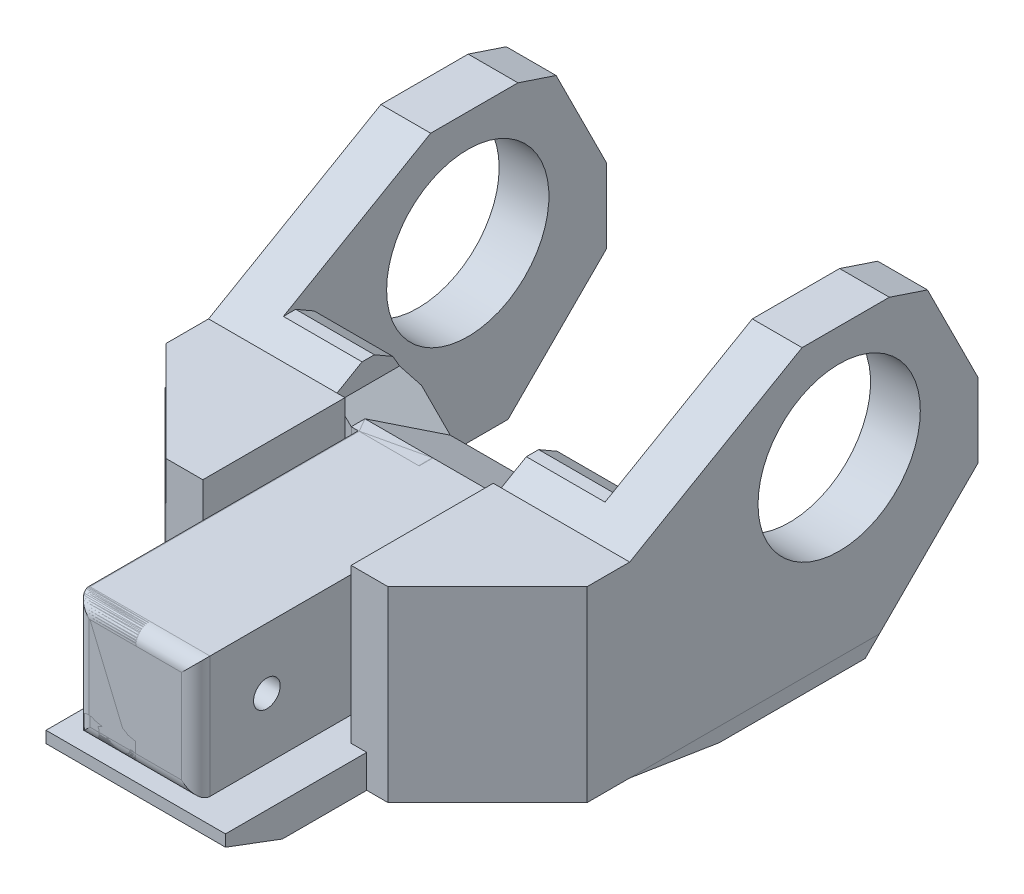
from build123d import *

# Parameters (mm, degrees)
BOSS_EXTRUDE1_DEPTH      = 21.73
BOSS_EXTRUDE2_DEPTH      = 23.229999974
BOSS_EXTRUDE2_DEPTH_BACK = 1.5
SKETCH2_W                = 19.05
SKETCH2_H                = 24.729999974
BOSS_EXTRUDE3_DEPTH      = 25.4
SKETCH3_W                = 6.35
SKETCH3_H                = 24.729999974
BOSS_EXTRUDE4_DEPTH      = 43.18
SKETCH4_W                = 19.05
SKETCH4_H                = 24.729999974
CUT_EXTRUDE1_DEPTH       = 14.05
SKETCH5_W                = 43.64
SKETCH5_H                = 24.729999974
BOSS_EXTRUDE5_DEPTH      = 7.62
BOSS_EXTRUDE6_DEPTH      = 8.789999946
BOSS_EXTRUDE7_DEPTH      = 20.219999946
SKETCH9_W                = 49.61
SKETCH9_H                = 53.739999866
BOSS_EXTRUDE8_DEPTH      = 2.54
SKETCH10_R               = 14.5
CUT_EXTRUDE2_DEPTH       = 44.704
FILLET3_R                = 2.54
CHAMFER1_SIZE            = 20.16
CHAMFER2_SIZE            = 20.32
CHAMFER2_SIZE2           = 10.16
SKETCH12_W               = 23.23
SKETCH12_H               = 21.71999992
CUT_EXTRUDE4_DEPTH       = 23.114
SKETCH13_W               = 12.62
SKETCH13_H               = 21.71999992
CUT_EXTRUDE5_DEPTH       = 3.81
CHAMFER4_SIZE            = 2.54
CHAMFER7_SIZE            = 17.78
CHAMFER7_SIZE2           = 30.795863359
CHAMFER8_SIZE            = 2.54
CHAMFER8_SIZE2           = 16.036928847
CHAMFER10_SIZE           = 12.7
CHAMFER10_SIZE2          = 6.35
SKETCH16_W               = 21.59
SKETCH16_H               = 33.419999866
BOSS_EXTRUDE9_DEPTH      = 25.4
BOSS_EXTRUDE10_DEPTH     = 25.4
CHAMFER12_SIZE           = 5.08
CHAMFER12_SIZE2          = 10.16
CHAMFER13_SIZE           = 2.54
CHAMFER13_SIZE2          = 5.679612663
SKETCH18_W               = 24.13
SKETCH18_H               = 29.479999946
BOSS_EXTRUDE11_DEPTH     = 25.4
SKETCH11_R               = 1.778
CUT_EXTRUDE9_DEPTH       = 131.296968124
CHAMFER14_SIZE           = 17.78
SKETCH19_W               = 29.67
SKETCH19_H               = 5.08
BOSS_EXTRUDE12_DEPTH     = 50.633268
CHAMFER15_SIZE           = 10.16
CHAMFER15_SIZE2          = 3.81
CUT_EXTRUDE10_DEPTH      = 122.202951668
CUT_EXTRUDE11_REACH      = 92.065
SKETCH21_W               = 24.13
SKETCH21_H               = 2.948571429
CUT_EXTRUDE13_DEPTH      = 26.67
CUT_EXTRUDE14_DEPTH      = 31.496
CHAMFER17_SIZE           = 2.54
CHAMFER17_SIZE2          = 4.399409051
CHAMFER18_SIZE           = 2.54
CHAMFER18_SIZE2          = 4.399409051
CHAMFER19_SIZE           = 1.27
SKETCH26_W               = 25.4
SKETCH26_H               = 28.339999866
BOSS_EXTRUDE13_DEPTH     = 2.785625036
BOSS_EXTRUDE14_DEPTH     = 0.8
SKETCH30_R               = 2.032
CUT_EXTRUDE16_DEPTH      = 89.17795503


with BuildPart() as part:
    # Sketch1 → Boss-Extrude1 (new body)
    with BuildSketch(Plane(origin=(0, 0, 0), x_dir=(1, 0, 0), z_dir=(0, 1, 0))):
        Polygon((-1.5, 40), (0, 40), (21.59, 40), (23.09, 40), (23.09, 45), (-1.5, 45), align=None)
        Polygon((0, 40), (0, 0), (0, -10.633268202), (21.59, -10.633268202), (21.59, 0), (21.59, 40), align=None)
    extrude(amount=BOSS_EXTRUDE1_DEPTH)

    # Sketch1_4 → Boss-Extrude2 (add, two sides)
    with BuildSketch(Plane(origin=(0, 0, 0), x_dir=(1, 0, 0), z_dir=(0, 1, 0))) as boss_extrude2_sk:
        Polygon((-1.5, 40), (0, 40), (21.59, 40), (23.09, 40), (23.09, 45), (-1.5, 45), align=None)
    extrude(amount=BOSS_EXTRUDE2_DEPTH)
    extrude(boss_extrude2_sk.sketch, amount=-BOSS_EXTRUDE2_DEPTH_BACK)

    # Sketch2 → Boss-Extrude3 (add)
    with BuildSketch(Plane(origin=(23.09, 0, 0), x_dir=(0, 0, -1), z_dir=(1, 0, 0))):
        with Locations((49.525, 10.864999987)):
            Rectangle(SKETCH2_W, SKETCH2_H)
    extrude(amount=BOSS_EXTRUDE3_DEPTH)

    # Sketch3 → Boss-Extrude4 (add)
    with BuildSketch(Plane(origin=(0, 0, -59.05), x_dir=(-1, 0, 0), z_dir=(0, 0, -1))):
        with Locations((-45.315, 10.864999987)):
            Rectangle(SKETCH3_W, SKETCH3_H)
    extrude(amount=BOSS_EXTRUDE4_DEPTH)

    # Sketch4 → Cut-Extrude1 (cut)
    with BuildSketch(Plane(origin=(0, 0, -59.05), x_dir=(-1, 0, 0), z_dir=(0, 0, -1))):
        with Locations((-32.615, 10.864999987)):
            Rectangle(SKETCH4_W, SKETCH4_H)
    extrude(amount=-CUT_EXTRUDE1_DEPTH, mode=Mode.SUBTRACT)

    # Sketch5 → Boss-Extrude5 (add)
    with BuildSketch(Plane(origin=(0, 0, -45), x_dir=(-1, 0, 0), z_dir=(0, 0, -1))):
        with Locations((-20.32, 10.864999987)):
            Rectangle(SKETCH5_W, SKETCH5_H)
    extrude(amount=BOSS_EXTRUDE5_DEPTH)

    # Sketch6 → Boss-Extrude6 (add)
    with BuildSketch(Plane.XZ.offset(1.5)):
        Polygon((-1.5, -40), (48.49, -40), (48.49, -46.27), (48.49, -102.23), (42.14, -102.23), (42.14, -52.62), (-1.5, -52.62), align=None)
    extrude(amount=BOSS_EXTRUDE6_DEPTH)

    # Sketch7 → Boss-Extrude7 (add)
    with BuildSketch(Plane(origin=(0, 23.229999974, 0), x_dir=(1, 0, 0), z_dir=(0, 1, 0))):
        Polygon((-1.5, 40), (48.49, 40), (48.49, 46.27), (48.49, 102.23), (42.14, 102.23), (42.14, 52.62), (-1.5, 52.62), align=None)
    extrude(amount=BOSS_EXTRUDE7_DEPTH)

    # Sketch9 → Boss-Extrude8 (add)
    with BuildSketch(Plane.ZY.offset(-42.14)):
        with Locations((-77.425, 16.579999987)):
            Rectangle(SKETCH9_W, SKETCH9_H)
    extrude(amount=BOSS_EXTRUDE8_DEPTH)

    # Sketch10 → Cut-Extrude2 (cut)
    with BuildSketch(Plane.ZY.offset(-39.6)):
        with Locations((-77.425, 23.12999992)):
            Circle(SKETCH10_R)
    extrude(amount=-CUT_EXTRUDE2_DEPTH, mode=Mode.SUBTRACT)

    # Fillet3
    fillet3_edges = [part.edges().sort_by_distance(p)[0] for p in [
        (10.795, 0, 10.633268202),
        (10.795, 21.73, 10.633268202),
        (21.59, 10.865, 10.633268202),
        (0, 10.865, 10.633268202),
    ]]
    fillet(fillet3_edges, radius=FILLET3_R)

    # Chamfer1
    chamfer1_edges = [part.edges().sort_by_distance(p)[0] for p in [
        (44.045, -10.289999946, -102.23),
    ]]
    chamfer(chamfer1_edges, length=CHAMFER1_SIZE)

    # Chamfer2
    chamfer2_edges = [part.edges().sort_by_distance(p)[0] for p in [
        (44.045, 43.44999992, -102.23),
    ]]
    chamfer2_side = [part.faces().sort_by_distance(p)[0] for p in [
        (44.045, 26.659999987, -102.23),
    ]]
    chamfer(chamfer2_edges, length=CHAMFER2_SIZE, length2=CHAMFER2_SIZE2, reference=chamfer2_side[0])

    # Sketch12 → Cut-Extrude4 (cut)
    with BuildSketch(Plane.XY.offset(-40)):
        with Locations((10.115, 32.58999996)):
            Rectangle(SKETCH12_W, SKETCH12_H)
    extrude(amount=-CUT_EXTRUDE4_DEPTH, mode=Mode.SUBTRACT)

    # Sketch13 → Cut-Extrude5 (cut)
    with BuildSketch(Plane.ZY.offset(-21.73)):
        with Locations((-46.31, 32.58999996)):
            Rectangle(SKETCH13_W, SKETCH13_H)
    extrude(amount=-CUT_EXTRUDE5_DEPTH, mode=Mode.SUBTRACT)

    # Chamfer4
    chamfer4_edges = [part.edges().sort_by_distance(p)[0] for p in [
        (25.54, 21.73, -46.31),
    ]]
    chamfer(chamfer4_edges, length=CHAMFER4_SIZE)

    # Chamfer7
    chamfer7_edges = [part.edges().sort_by_distance(p)[0] for p in [
        (37.015, 43.44999992, -40),
    ]]
    chamfer7_side = [part.faces().sort_by_distance(p)[0] for p in [
        (31.271893958, 12.476304807, -40),
    ]]
    chamfer(chamfer7_edges, length=CHAMFER7_SIZE, length2=CHAMFER7_SIZE2, reference=chamfer7_side[0])

    # Chamfer8
    chamfer8_edges = [part.edges().sort_by_distance(p)[0] for p in [
        (23.495, -10.289999946, -40),
    ]]
    chamfer8_side = [part.faces().sort_by_distance(p)[0] for p in [
        (29.3591267, 5.121230979, -40),
    ]]
    chamfer(chamfer8_edges, length=CHAMFER8_SIZE, length2=CHAMFER8_SIZE2, reference=chamfer8_side[0])

    # Chamfer10
    chamfer10_edges = [part.edges().sort_by_distance(p)[0] for p in [
        (39.6, 11.603674367, -52.62),
    ]]
    chamfer10_side = [part.faces().sort_by_distance(p)[0] for p in [
        (20.529332087, 8.343955773, -52.62),
    ]]
    chamfer(chamfer10_edges, length=CHAMFER10_SIZE, length2=CHAMFER10_SIZE2, reference=chamfer10_side[0])

    # Sketch16 → Boss-Extrude9 (add)
    with BuildSketch(Plane.XY.offset(-40)):
        with Locations((37.695, 8.959999987)):
            Rectangle(SKETCH16_W, SKETCH16_H)
    extrude(amount=BOSS_EXTRUDE9_DEPTH)

    # Sketch17 → Boss-Extrude10 (add)
    with BuildSketch(Plane.ZY.offset(1.5)):
        Polygon((-52.62, 21.73), (-52.62, -9.748811583), (-40, -7.749999946), (-40, 21.73), align=None)
    extrude(amount=BOSS_EXTRUDE10_DEPTH)

    # Chamfer12
    chamfer12_edges = [part.edges().sort_by_distance(p)[0] for p in [
        (-1.95, 21.73, -52.62),
    ]]
    chamfer12_side = [part.faces().sort_by_distance(p)[0] for p in [
        (0.280348521, 6.212260244, -52.62),
    ]]
    chamfer(chamfer12_edges, length=CHAMFER12_SIZE, length2=CHAMFER12_SIZE2, reference=chamfer12_side[0])

    # Chamfer13
    chamfer13_edges = [part.edges().sort_by_distance(p)[0] for p in [
        (44.045, 43.44999992, -92.07),
    ]]
    chamfer13_side = [part.faces().sort_by_distance(p)[0] for p in [
        (44.045, 33.28999992, -97.15),
    ]]
    chamfer(chamfer13_edges, length=CHAMFER13_SIZE, length2=CHAMFER13_SIZE2, reference=chamfer13_side[0])

    # Sketch18 → Boss-Extrude11 (add)
    with BuildSketch(Plane.XY.offset(-40)):
        with Locations((-14.835, 6.990000027)):
            Rectangle(SKETCH18_W, SKETCH18_H)
    extrude(amount=BOSS_EXTRUDE11_DEPTH)

    # Sketch11 → Cut-Extrude9 (cut, through all)
    with BuildSketch(Plane.XY.offset(10.633268202)):
        with Locations((2.54, 2.54)):
            Circle(SKETCH11_R)
    extrude(amount=-CUT_EXTRUDE9_DEPTH, mode=Mode.SUBTRACT)

    # Chamfer14
    chamfer14_edges = [part.edges().sort_by_distance(p)[0] for p in [
        (48.49, 8.959999987, -14.6),
        (-26.9, 6.990000027, -14.6),
    ]]
    chamfer(chamfer14_edges, length=CHAMFER14_SIZE)

    # Sketch19 → Boss-Extrude12 (add, through all)
    with BuildSketch(Plane.XY.offset(-40)):
        with Locations((12.065, -5.209999946)):
            Rectangle(SKETCH19_W, SKETCH19_H)
    extrude(amount=BOSS_EXTRUDE12_DEPTH)

    # Chamfer15
    chamfer15_edges = [part.edges().sort_by_distance(p)[0] for p in [
        (12.065, -7.749999946, 10.633268),
    ]]
    chamfer15_side = [part.faces().sort_by_distance(p)[0] for p in [
        (11.2000407, -7.749999946, -20.137931454),
    ]]
    chamfer(chamfer15_edges, length=CHAMFER15_SIZE, length2=CHAMFER15_SIZE2, reference=chamfer15_side[0])

    # Sketch20 → Cut-Extrude10 (cut, through all)
    with BuildSketch(Plane.ZY):
        with BuildLine():
            ThreePointArc((0.314518202, 10.865), (-0.382933775, 12.548798023), (-2.066731798, 13.24625))
            Line((-2.066731798, 13.24625), (-2.066731798, 10.865))
            Line((-2.066731798, 10.865), (0.314518202, 10.865))
        make_face()
        with BuildLine():
            Line((-2.066731798, 10.865), (-2.066731798, 13.24625))
            ThreePointArc((-2.066731798, 13.24625), (-3.750529821, 9.181201977), (0.314518202, 10.865))
            Line((0.314518202, 10.865), (-2.066731798, 10.865))
        make_face()
    extrude(amount=-CUT_EXTRUDE10_DEPTH, mode=Mode.SUBTRACT)

    # Cut-Extrude11: up to this face of the body (flat: up to its plane)
    cut_extrude11_end = Plane(part.part.faces().sort_by_distance((-5.945, 6.990000027, -14.6))[0])
    # Sketch21 → Cut-Extrude11 (cut, up to the picked face)
    with BuildSketch(Plane(origin=(0, 0, -40), x_dir=(-1, 0, 0), z_dir=(0, 0, -1)), mode=Mode.PRIVATE) as cut_extrude11_sk1:
        with Locations((14.835, 20.255714286)):
            Rectangle(SKETCH21_W, SKETCH21_H)
    cut_extrude11_tool1 = split(extrude(cut_extrude11_sk1.sketch, amount=-CUT_EXTRUDE11_REACH, mode=Mode.PRIVATE), bisect_by=cut_extrude11_end, keep=Keep.BOTH, mode=Mode.PRIVATE)
    add(cut_extrude11_tool1.solids().sort_by(Axis((-14.835, 20.255714, -40), (0, 0, 1)))[0], mode=Mode.SUBTRACT)


with BuildPart() as body_2:
    # Split1: the piece on the far side of the plane
    add(part.part)
    split(bisect_by=Plane(origin=(0, -7.749999946, 0), x_dir=(0, 0, -1), z_dir=(0, -1, 0)), keep=Keep.BOTTOM)


with BuildPart() as part_1:
    add(part.part)

    # Split1
    split(bisect_by=Plane(origin=(0, -7.749999946, 0), x_dir=(0, 0, -1), z_dir=(0, -1, 0)), keep=Keep.TOP)


with BuildPart() as body_3:
    # Split2: the piece on the far side of the plane
    add(body_2.part)
    split(bisect_by=Plane(origin=(10.865000114, 0, 0), x_dir=(0, 0, -1), z_dir=(-1, 0, 0)), keep=Keep.BOTTOM)


with BuildPart() as body_2_1:
    add(body_2.part)

    # Split2
    split(bisect_by=Plane(origin=(10.865000114, 0, 0), x_dir=(0, 0, -1), z_dir=(-1, 0, 0)), keep=Keep.TOP)


with BuildPart() as body_4:
    # Mirror2: mirrored copy
    add(body_3.part.mirror(Plane.ZY.offset(-10.865000114)))

    # Combine1: union body 3
    add(body_3.part)

    # Sketch24 → Cut-Extrude13 (cut)
    with BuildSketch(Plane(origin=(0, 1.931991864, 1.115436023), x_dir=(1, 0, 0), z_dir=(0, 0.8660254037844406, 0.4999999999999968))):
        Polygon((-3.809999772, 62.048336906), (-3.809999772, 56.460336906), (-17.869999772, 56.460336906), (-17.869999772, 69.380685324), (-5.169999772, 62.048336906), align=None)
    cut_extrude13 = extrude(amount=-CUT_EXTRUDE13_DEPTH, mode=Mode.SUBTRACT)

    # Mirror3: Cut-Extrude13 across plane
    add(cut_extrude13.mirror(Plane.ZY.offset(-10.865000114)), mode=Mode.SUBTRACT)

    # Sketch25 → Cut-Extrude14 (cut)
    with BuildSketch(Plane(origin=(25.54, 0, 0), x_dir=(0, 0, -1), z_dir=(1, 0, 0))):
        Polygon((52.62, 21.780160317), (51.182490389, 24.27), (52.62, 24.27), align=None)
    extrude(amount=-CUT_EXTRUDE14_DEPTH, mode=Mode.SUBTRACT)

    # Chamfer17
    chamfer17_edges = [body_4.edges().sort_by_distance(p)[0] for p in [
        (32.57, 30.162160317, -47.780650044),
    ]]
    chamfer17_side = [body_4.faces().sort_by_distance(p)[0] for p in [
        (40.768870369, 32.663150898, -52.112492799),
    ]]
    chamfer(chamfer17_edges, length=CHAMFER17_SIZE, length2=CHAMFER17_SIZE2, reference=chamfer17_side[0])

    # Chamfer18
    chamfer18_edges = [body_4.edges().sort_by_distance(p)[0] for p in [
        (-10.839999772, 30.162160317, -47.780650044),
    ]]
    chamfer18_side = [body_4.faces().sort_by_distance(p)[0] for p in [
        (-19.038870141, 32.663150898, -52.112492799),
    ]]
    chamfer(chamfer18_edges, length=CHAMFER18_SIZE, length2=CHAMFER18_SIZE2, reference=chamfer18_side[0])

    # Chamfer19
    chamfer19_edges = [body_4.edges().sort_by_distance(p)[0] for p in [
        (32.57, 28.892160317, -45.580945518),
        (-10.839999772, 28.892160317, -45.580945518),
    ]]
    chamfer(chamfer19_edges, length=CHAMFER19_SIZE)

    # Sketch26 → Boss-Extrude13 (add)
    with BuildSketch(Plane.ZY.offset(-26.9)):
        with Locations((-27.3, 11.499999987)):
            Rectangle(SKETCH26_W, SKETCH26_H)
    boss_extrude13 = extrude(amount=BOSS_EXTRUDE13_DEPTH)

    # Mirror4: Boss-Extrude13 across plane
    add(boss_extrude13.mirror(Plane.ZY.offset(-10.865000162)))

    # Sketch27 → Boss-Extrude14 (add)
    with BuildSketch(Plane(origin=(0, -2.669999946, 0), x_dir=(1, 0, 0), z_dir=(0, 1, 0))):
        Polygon((24.114374964, 14.6), (26.9, 14.6), (26.9, -10.633268202), (-5.169999676, -10.633268202), (-5.169999676, 14.6), (-2.38437464, 14.6), (-2.38437464, 40), (24.114374964, 40), align=None)
    extrude(amount=BOSS_EXTRUDE14_DEPTH)

    # Sketch30 → Cut-Extrude16 (cut, through all)
    with BuildSketch(Plane(origin=(9.809684221, 0, -55.633483781), x_dir=(0, -1, 0), z_dir=(0.17364817766693072, 0, -0.984807753012208))):
        with Locations(Location((-3.269376543, -9.695540697, 0), (0, 0, 68.96457184))):
            Circle(SKETCH30_R)
    extrude(amount=-CUT_EXTRUDE16_DEPTH, mode=Mode.SUBTRACT)


solid = Compound([part_1.part, body_2_1.part, body_4.part])
